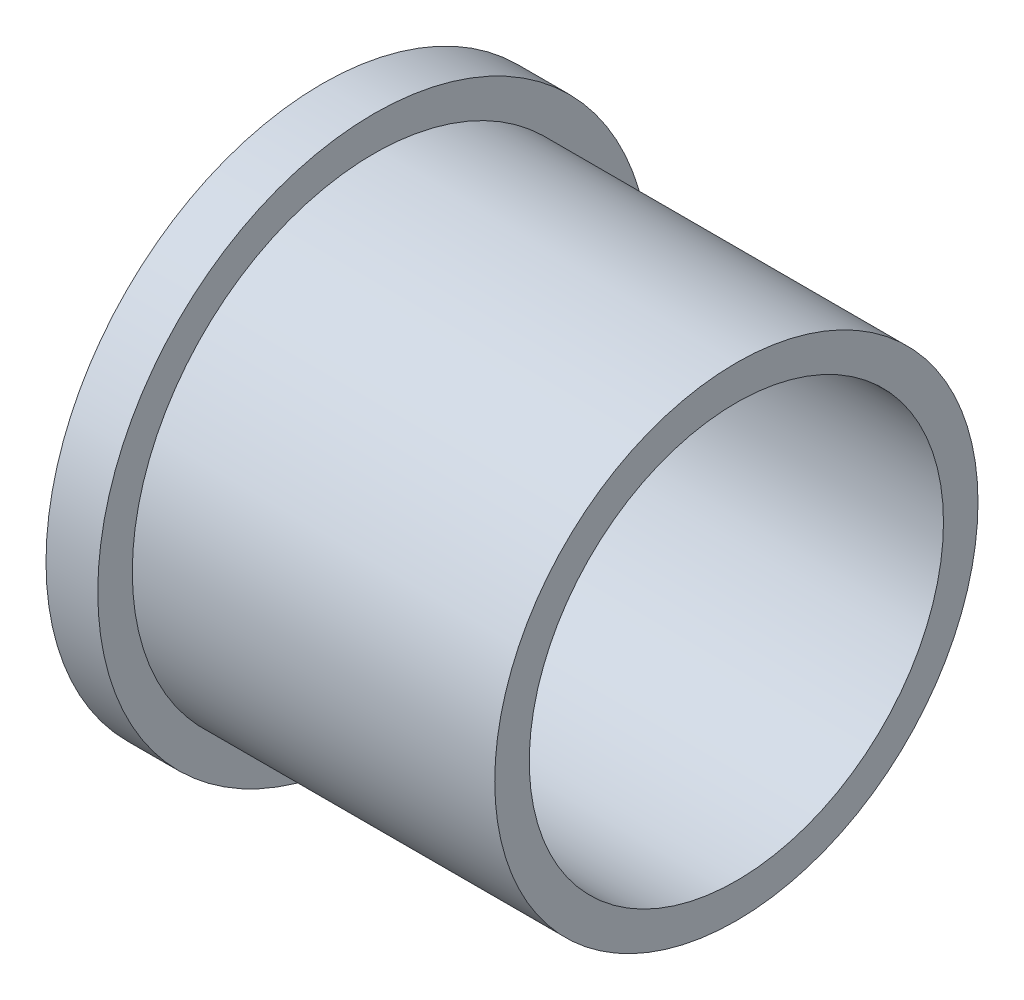
from build123d import *

# Parameters (mm, degrees)
SKETCH1_R           = 22.225
SKETCH1_R_2         = 19.05
BOSS_EXTRUDE1_DEPTH = 38.1
SKETCH2_R           = 25.4
SKETCH2_R_2         = 22.225
BOSS_EXTRUDE2_DEPTH = 4.7625


with BuildPart() as part:
    # Sketch1 → Boss-Extrude1 (new body)
    with BuildSketch(Plane(origin=(0, 0, 0), x_dir=(0, 0, -1), z_dir=(1, 0, 0))):
        Circle(SKETCH1_R)
        Circle(SKETCH1_R_2, mode=Mode.SUBTRACT)
    extrude(amount=BOSS_EXTRUDE1_DEPTH)

    # Sketch2 → Boss-Extrude2 (add)
    with BuildSketch(Plane.ZY):
        Circle(SKETCH2_R)
        Circle(SKETCH2_R_2, mode=Mode.SUBTRACT)
    extrude(amount=-BOSS_EXTRUDE2_DEPTH)


solid = part.part
